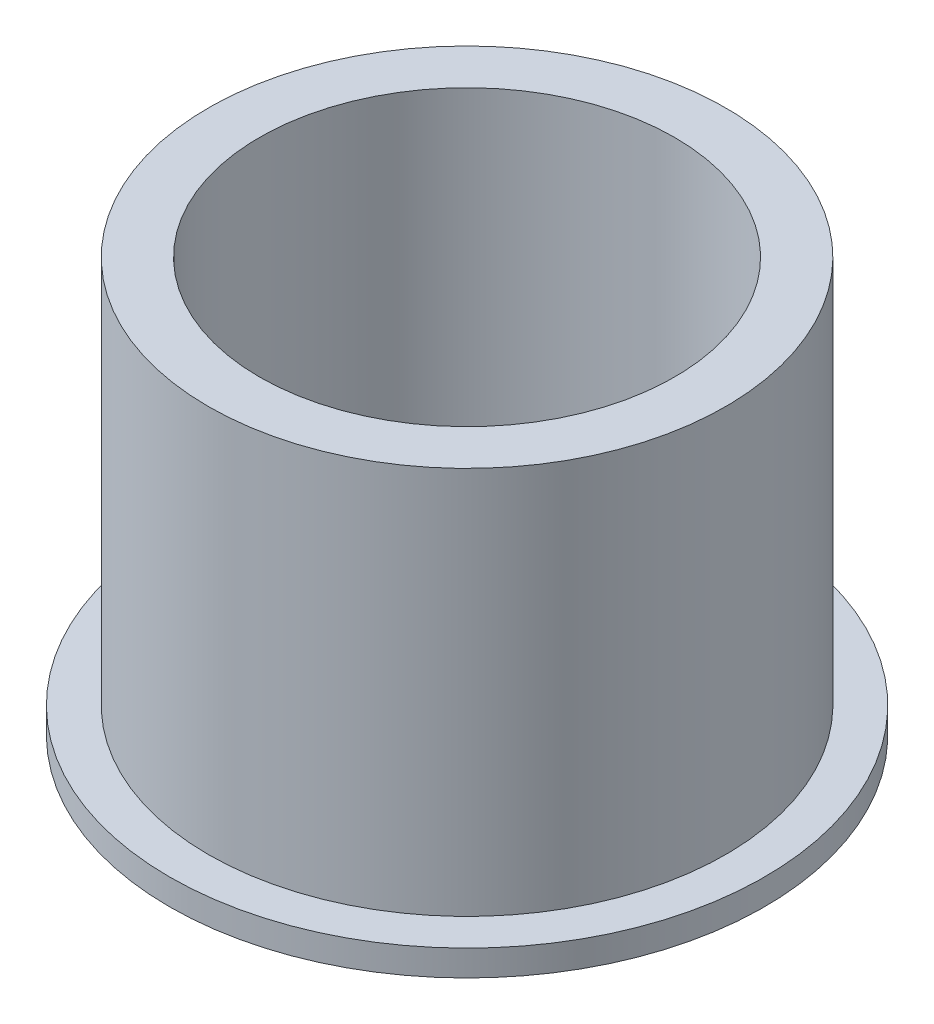
from build123d import *

# Parameters (mm, degrees)
SKETCH2_R           = 15.875
SKETCH2_R_2         = 12.7381
BOSS_EXTRUDE1_DEPTH = 25.4
SKETCH3_R           = 18.25625
SKETCH3_R_2         = 15.875
BOSS_EXTRUDE2_DEPTH = 1.5875


with BuildPart() as part:
    # Sketch2 → Boss-Extrude1 (new body)
    with BuildSketch(Plane(origin=(0, 0, 0), x_dir=(1, 0, 0), z_dir=(0, 1, 0))):
        Circle(SKETCH2_R)
        Circle(SKETCH2_R_2, mode=Mode.SUBTRACT)
    extrude(amount=BOSS_EXTRUDE1_DEPTH)

    # Sketch3 → Boss-Extrude2 (add)
    with BuildSketch(Plane(origin=(0, 0, 0), x_dir=(1, 0, 0), z_dir=(0, 1, 0))):
        Circle(SKETCH3_R)
        Circle(SKETCH3_R_2, mode=Mode.SUBTRACT)
    extrude(amount=BOSS_EXTRUDE2_DEPTH)


solid = part.part
